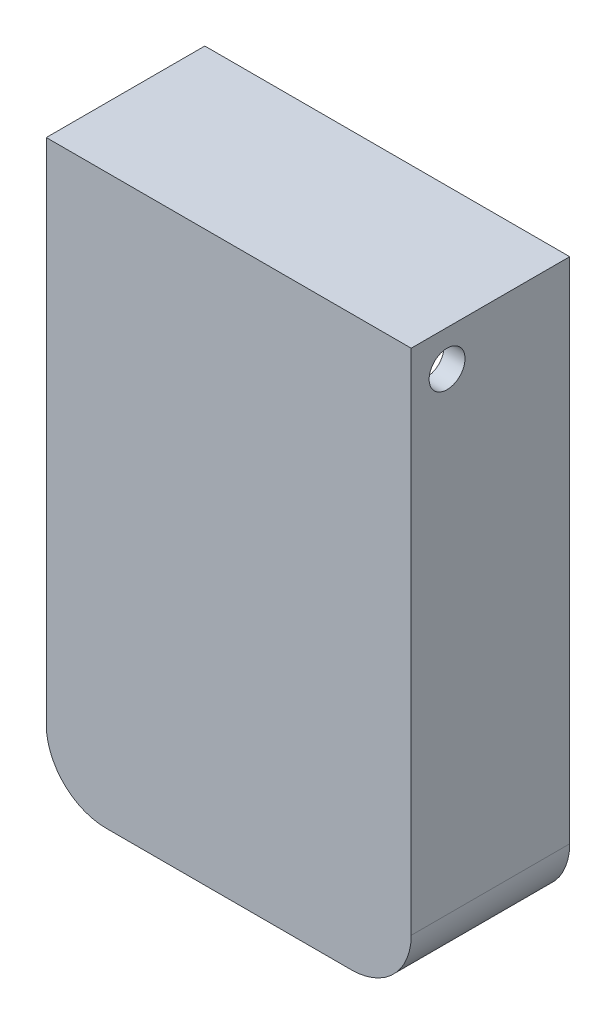
from build123d import *

# Parameters (mm, degrees)
SKETCH1_W               = 61
SKETCH1_H               = 95
BOSS_EXTRUDE1_DEPTH     = 25
SHELL1_T                = -1.5
FILLET1_R               = 10
SKETCH2_R               = 3
SKETCH2_R_2             = 1.4
BOSS_EXTRUDE2_DEPTH     = 4
SKETCH4_W               = 2
SKETCH4_H               = 18
BOSS_EXTRUDE3_DEPTH     = 23.5
SKETCH3_R               = 3
CUT_EXTRUDE1_DEPTH      = 1
CUT_EXTRUDE1_DEPTH_BACK = 62
BOSS_EXTRUDE4_DEPTH     = 1.5
SKETCH6_W               = 59.5
SKETCH6_H               = 4.25
BOSS_EXTRUDE5_DEPTH     = 1.5
SKETCH7_W               = 52
SKETCH7_H               = 1
BOSS_EXTRUDE6_DEPTH     = 1
FILLET2_R               = 0.3
BOSS_EXTRUDE7_DEPTH     = 19.5
SKETCH9_R               = 1.4
CUT_EXTRUDE2_DEPTH      = 10


with BuildPart() as part:
    # Sketch1 → Boss-Extrude1 (new body)
    with BuildSketch(Plane.XY):
        Rectangle(SKETCH1_W, SKETCH1_H)
    extrude(amount=BOSS_EXTRUDE1_DEPTH)

    # Shell1
    shell1_openings = [part.faces().sort_by_distance(p)[0] for p in [
        (0, 0, 0),
    ]]
    offset(amount=SHELL1_T, openings=shell1_openings, kind=Kind.INTERSECTION)

    # Fillet1
    fillet1_edges = [part.edges().sort_by_distance(p)[0] for p in [
        (29, -46, 11.75),
        (-29, -46, 11.75),
        (30.5, -47.5, 12.5),
        (-30.5, -47.5, 12.5),
    ]]
    fillet(fillet1_edges, radius=FILLET1_R)

    # Sketch2 → Boss-Extrude2 (add)
    with BuildSketch(Plane(origin=(0, 0, 23.5), x_dir=(-1, 0, 0), z_dir=(0, 0, -1))):
        with Locations((-21.5, 12)):
            Circle(SKETCH2_R)
        with Locations((-21.5, 12)):
            Circle(SKETCH2_R_2, mode=Mode.SUBTRACT)
        with Locations((-21.5, -31)):
            Circle(SKETCH2_R)
        with Locations((-21.5, -31)):
            Circle(SKETCH2_R_2, mode=Mode.SUBTRACT)
        with Locations((21.5, -31)):
            Circle(SKETCH2_R)
        with Locations((21.5, -31)):
            Circle(SKETCH2_R_2, mode=Mode.SUBTRACT)
    extrude(amount=BOSS_EXTRUDE2_DEPTH)

    # Sketch4 → Boss-Extrude3 (add)
    with BuildSketch(Plane(origin=(0, 0, 23.5), x_dir=(-1, 0, 0), z_dir=(0, 0, -1))):
        with Locations((-28, 37)):
            Rectangle(SKETCH4_W, SKETCH4_H)
        with Locations((28, 37)):
            Rectangle(SKETCH4_W, SKETCH4_H)
    extrude(amount=BOSS_EXTRUDE3_DEPTH)

    # Sketch3 → Cut-Extrude1 (cut, two sides)
    with BuildSketch(Plane(origin=(30.5, 0, 0), x_dir=(0, 0, -1), z_dir=(1, 0, 0))) as cut_extrude1_sk:
        with Locations((-19, 41.5)):
            Circle(SKETCH3_R)
    extrude(amount=CUT_EXTRUDE1_DEPTH, mode=Mode.SUBTRACT)
    extrude(cut_extrude1_sk.sketch, amount=-CUT_EXTRUDE1_DEPTH_BACK, mode=Mode.SUBTRACT)

    # Sketch5 → Boss-Extrude4 (add)
    with BuildSketch(Plane(origin=(0, 0, 0), x_dir=(-1, 0, 0), z_dir=(0, 0, -1))):
        with BuildLine():
            Line((-30.5, 47.5), (30.5, 47.5))
            Line((30.5, 47.5), (30.5, -37.5))
            ThreePointArc((30.5, -37.5), (27.571067812, -44.571067812), (20.5, -47.5))
            Line((20.5, -47.5), (-20.5, -47.5))
            ThreePointArc((-20.5, -47.5), (-27.571067812, -44.571067812), (-30.5, -37.5))
            Line((-30.5, -37.5), (-30.5, 47.5))
        make_face()
        with BuildLine():
            Line((-19.75, -46.75), (19.75, -46.75))
            ThreePointArc((19.75, -46.75), (26.821067812, -43.821067812), (29.75, -36.75))
            Line((29.75, -36.75), (29.75, 46.75))
            Line((29.75, 46.75), (-29.75, 46.75))
            Line((-29.75, 46.75), (-29.75, -36.75))
            ThreePointArc((-29.75, -36.75), (-26.821067812, -43.821067812), (-19.75, -46.75))
        make_face(mode=Mode.SUBTRACT)
    extrude(amount=BOSS_EXTRUDE4_DEPTH)

    # Sketch6 → Boss-Extrude5 (add)
    with BuildSketch(Plane(origin=(0, 0, 0), x_dir=(-1, 0, 0), z_dir=(0, 0, -1))):
        with Locations((0, 44.625)):
            Rectangle(SKETCH6_W, SKETCH6_H)
    extrude(amount=BOSS_EXTRUDE5_DEPTH)

    # Sketch7 → Boss-Extrude6 (add)
    with BuildSketch(Plane.XY):
        with Locations((0, 43)):
            Rectangle(SKETCH7_W, SKETCH7_H)
    extrude(amount=BOSS_EXTRUDE6_DEPTH)

    # Fillet2
    fillet2_edges = [part.edges().sort_by_distance(p)[0] for p in [
        (0, 43.5, 1),
        (0, 42.5, 1),
    ]]
    fillet(fillet2_edges, radius=FILLET2_R)

    # Sketch8 → Boss-Extrude7 (add)
    with BuildSketch(Plane(origin=(0, 0, 23.5), x_dir=(-1, 0, 0), z_dir=(0, 0, -1))):
        with BuildLine():
            Line((-22.5, -36.5), (-28.987492178, -36.5))
            Line((-28.987492178, -36.5), (-28.987492178, -39))
            ThreePointArc((-28.987492178, -39), (-26.937239646, -43.949747468), (-21.987492178, -46))
            Line((-21.987492178, -46), (-19.5, -46))
            Line((-19.5, -46), (-19.5, -39.5))
            ThreePointArc((-19.5, -39.5), (-20.378679656, -37.378679656), (-22.5, -36.5))
        make_face()
        with BuildLine():
            Line((19.5, -46), (19.5, -39.5))
            ThreePointArc((19.5, -39.5), (20.378679656, -37.378679656), (22.5, -36.5))
            Line((22.5, -36.5), (28.987492178, -36.5))
            Line((28.987492178, -36.5), (28.987492178, -39))
            ThreePointArc((28.987492178, -39), (26.937239646, -43.949747468), (21.987492178, -46))
            Line((21.987492178, -46), (19.5, -46))
        make_face()
    extrude(amount=BOSS_EXTRUDE7_DEPTH)

    # Sketch9 → Cut-Extrude2 (cut)
    with BuildSketch(Plane(origin=(0, 0, 4), x_dir=(-1, 0, 0), z_dir=(0, 0, -1))):
        with Locations((-23, -40)):
            Circle(SKETCH9_R)
        with Locations((23, -40)):
            Circle(SKETCH9_R)
    extrude(amount=-CUT_EXTRUDE2_DEPTH, mode=Mode.SUBTRACT)


solid = part.part
